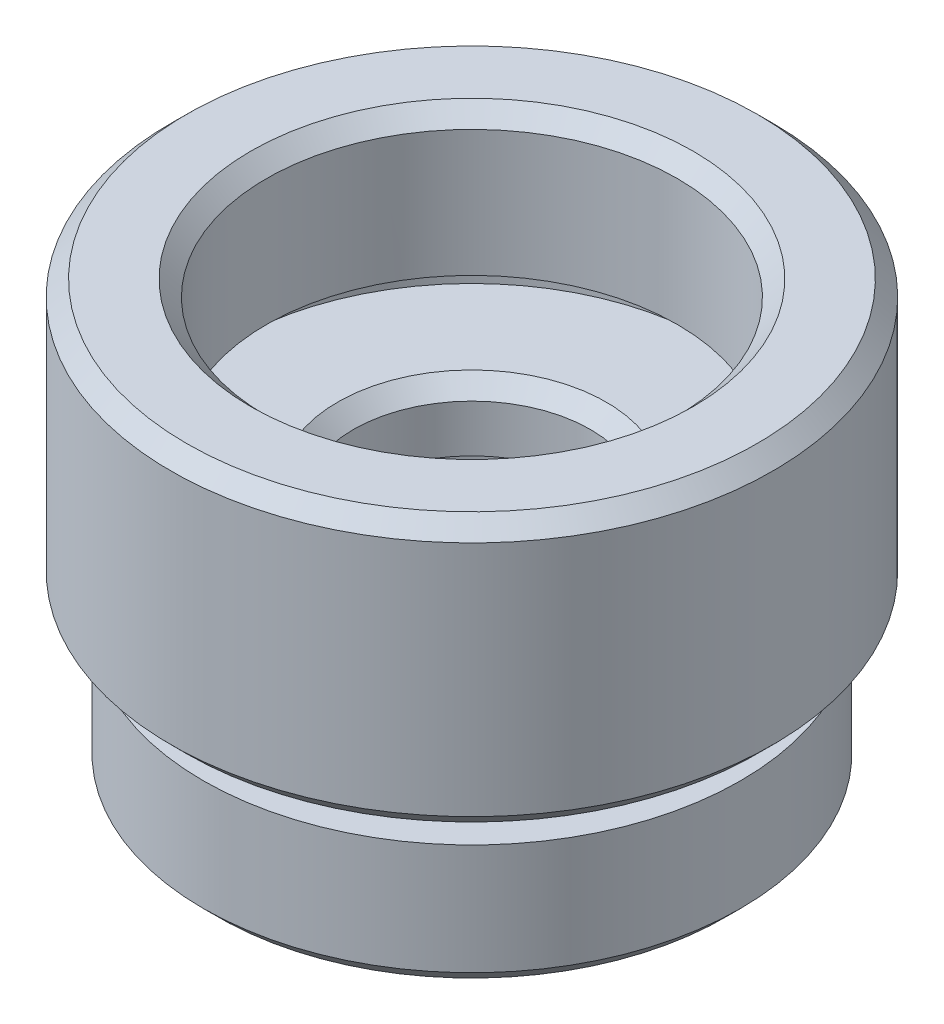
from build123d import *

# Parameters (mm, degrees)
CHAMFER_1_SIZE = 0.5


with BuildPart() as part:
    # 草图1 → 旋转1 (revolve)
    with BuildSketch(Plane.XY, mode=Mode.PRIVATE) as revolve_1_sk:
        Polygon((2.75, 0), (2.75, 2), (3.15, 2), (3.15, 5), (4.85, 5), (4.85, 6), (3.75, 6), (3.75, 8), (7.6, 8), (7.6, 9), (6.5, 9), (6.5, 13.5), (9.025, 13.5), (9.525, 13), (9.525, 5.5), (9.025, 5), (7, 5), (7, 4), (8.5, 4), (8.5, 0.5), (8, 0), align=None)
    revolve(revolve_1_sk.sketch.rotate(Axis((0, 0, 0), (0, 1, 0)), 90), axis=Axis((0, 0, 0), (0, 1, 0)))  # turned: the seam where the file's is

    # 倒角1
    chamfer_1_edges = [part.edges().sort_by_distance(p)[0] for p in [
        (0, 8, 3.75),
        (0, 13.5, 6.5),
    ]]
    chamfer(chamfer_1_edges, length=CHAMFER_1_SIZE)


solid = part.part
